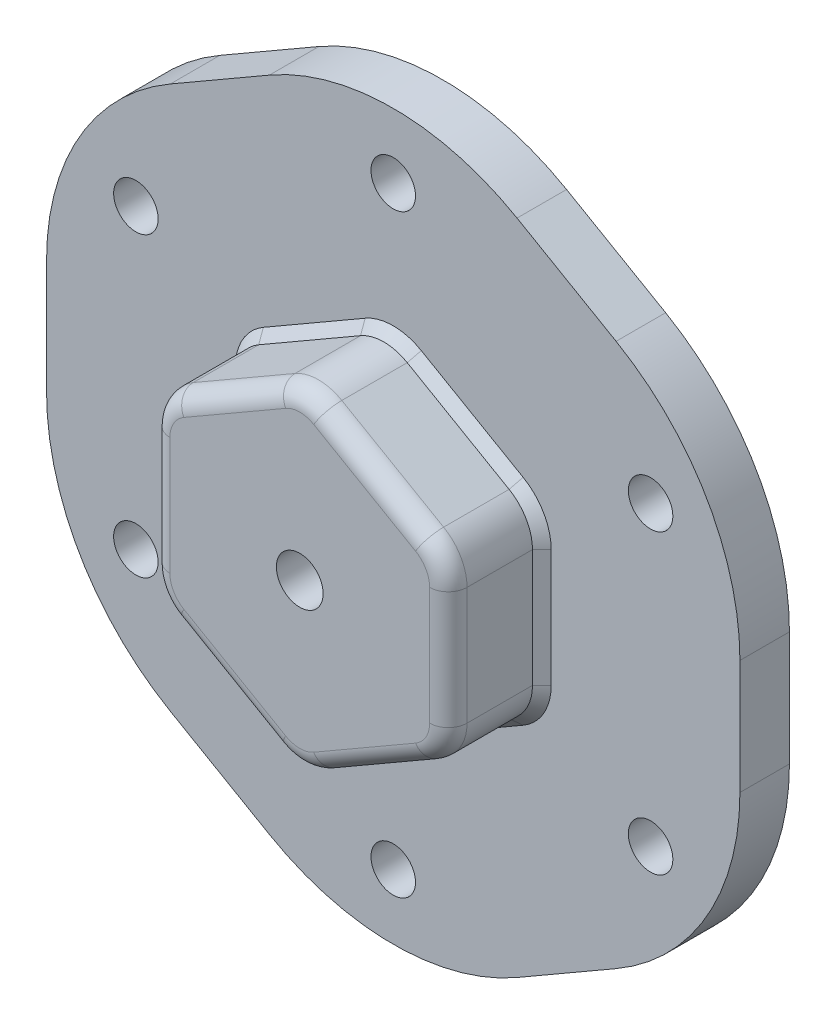
from build123d import *

# Parameters (mm, degrees)
SKETCH1_R             = 2.38125
BOSS_EXTRUDE1_DEPTH   = 5.298013245
SKETCH3_R             = 2.5
BOSS_EXTRUDE4_DEPTH   = 10
CHAMFER2_SIZE         = 1
FILLET1_R             = 2
CROQUIS1_R            = 2.5
CORTAR_EXTRUIR1_DEPTH = 10


with BuildPart() as part:
    # Sketch1 → Boss-Extrude1 (new body)
    with BuildSketch(Plane.XY):
        with BuildLine():
            Line((-13.245033113, 35.176307792), (-23.841059603, 29.058689045))
            ThreePointArc((-23.841059603, 29.058689045), (-33.537096789, 19.362651859), (-37.086092715, 6.117618746))
            Line((-37.086092715, 6.117618746), (-37.086092715, -6.117618746))
            ThreePointArc((-37.086092715, -6.117618746), (-33.537096789, -19.362651859), (-23.841059603, -29.058689045))
            Line((-23.841059603, -29.058689045), (-13.245033113, -35.176307792))
            ThreePointArc((-13.245033113, -35.176307792), (0, -38.725303718), (13.245033113, -35.176307792))
            Line((13.245033113, -35.176307792), (23.841059603, -29.058689045))
            ThreePointArc((23.841059603, -29.058689045), (33.537096789, -19.362651859), (37.086092715, -6.117618746))
            Line((37.086092715, -6.117618746), (37.086092715, 6.117618746))
            ThreePointArc((37.086092715, 6.117618746), (33.537096789, 19.362651859), (23.841059603, 29.058689045))
            Line((23.841059603, 29.058689045), (13.245033113, 35.176307792))
            ThreePointArc((13.245033113, 35.176307792), (0, 38.725303718), (-13.245033113, 35.176307792))
        make_face()
        with Locations((0, 31.78807947)):
            Circle(SKETCH1_R, mode=Mode.SUBTRACT)
        with Locations((27.529284359, 15.894039735)):
            Circle(SKETCH1_R, mode=Mode.SUBTRACT)
        with Locations((27.529284359, -15.894039735)):
            Circle(SKETCH1_R, mode=Mode.SUBTRACT)
        with Locations((0, -31.78807947)):
            Circle(SKETCH1_R, mode=Mode.SUBTRACT)
        with Locations((-27.529284359, -15.894039735)):
            Circle(SKETCH1_R, mode=Mode.SUBTRACT)
        with Locations((-27.529284359, 15.894039735)):
            Circle(SKETCH1_R, mode=Mode.SUBTRACT)
    extrude(amount=BOSS_EXTRUDE1_DEPTH)

    # Sketch3 → Boss-Extrude4 (add)
    with BuildSketch(Plane.XY.offset(5.298013245)):
        with BuildLine():
            Line((-2.5, 16.909480566), (-13.394039735, 10.619803793))
            ThreePointArc((-13.394039735, 10.619803793), (-15.224166754, 8.789676774), (-15.894039735, 6.289676774))
            Line((-15.894039735, 6.289676774), (-15.894039735, -6.289676774))
            ThreePointArc((-15.894039735, -6.289676774), (-15.224166754, -8.789676774), (-13.394039735, -10.619803793))
            Line((-13.394039735, -10.619803793), (-2.5, -16.909480566))
            ThreePointArc((-2.5, -16.909480566), (0, -17.579353547), (2.5, -16.909480566))
            Line((2.5, -16.909480566), (13.394039735, -10.619803793))
            ThreePointArc((13.394039735, -10.619803793), (15.224166754, -8.789676774), (15.894039735, -6.289676774))
            Line((15.894039735, -6.289676774), (15.894039735, 6.289676774))
            ThreePointArc((15.894039735, 6.289676774), (15.224166754, 8.789676774), (13.394039735, 10.619803793))
            Line((13.394039735, 10.619803793), (2.5, 16.909480566))
            ThreePointArc((2.5, 16.909480566), (0, 17.579353547), (-2.5, 16.909480566))
        make_face()
        Circle(SKETCH3_R, mode=Mode.SUBTRACT)
    extrude(amount=BOSS_EXTRUDE4_DEPTH)

    # Chamfer2
    chamfer2_edges = [part.edges().sort_by_distance(p)[0] for p in [
        (15.224166754, 8.789676774, 5.298013245),
        (7.947019868, 13.764642179, 5.298013245),
        (0, 17.579353547, 5.298013245),
        (-7.947019868, 13.764642179, 5.298013245),
        (-15.224166754, 8.789676774, 5.298013245),
        (-15.894039735, 0, 5.298013245),
        (-15.224166754, -8.789676774, 5.298013245),
        (-7.947019868, -13.764642179, 5.298013245),
        (0, -17.579353547, 5.298013245),
        (7.947019868, -13.764642179, 5.298013245),
        (15.224166754, -8.789676774, 5.298013245),
        (15.894039735, 0, 5.298013245),
    ]]
    chamfer(chamfer2_edges, length=CHAMFER2_SIZE)

    # Fillet1
    fillet1_edges = [part.edges().sort_by_distance(p)[0] for p in [
        (15.224166754, 8.789676774, 15.298013245),
        (7.947019868, 13.764642179, 15.298013245),
        (0, 17.579353547, 15.298013245),
        (-7.947019868, 13.764642179, 15.298013245),
        (-15.224166754, 8.789676774, 15.298013245),
        (-15.894039735, 0, 15.298013245),
        (-15.224166754, -8.789676774, 15.298013245),
        (-7.947019868, -13.764642179, 15.298013245),
        (0, -17.579353547, 15.298013245),
        (7.947019868, -13.764642179, 15.298013245),
        (15.224166754, -8.789676774, 15.298013245),
        (15.894039735, 0, 15.298013245),
    ]]
    fillet(fillet1_edges, radius=FILLET1_R)

    # Croquis1 → Cortar-Extruir1 (cut)
    with BuildSketch(Plane.XY.offset(5.298013245)):
        Circle(CROQUIS1_R)
    extrude(amount=-CORTAR_EXTRUIR1_DEPTH, mode=Mode.SUBTRACT)


solid = part.part
